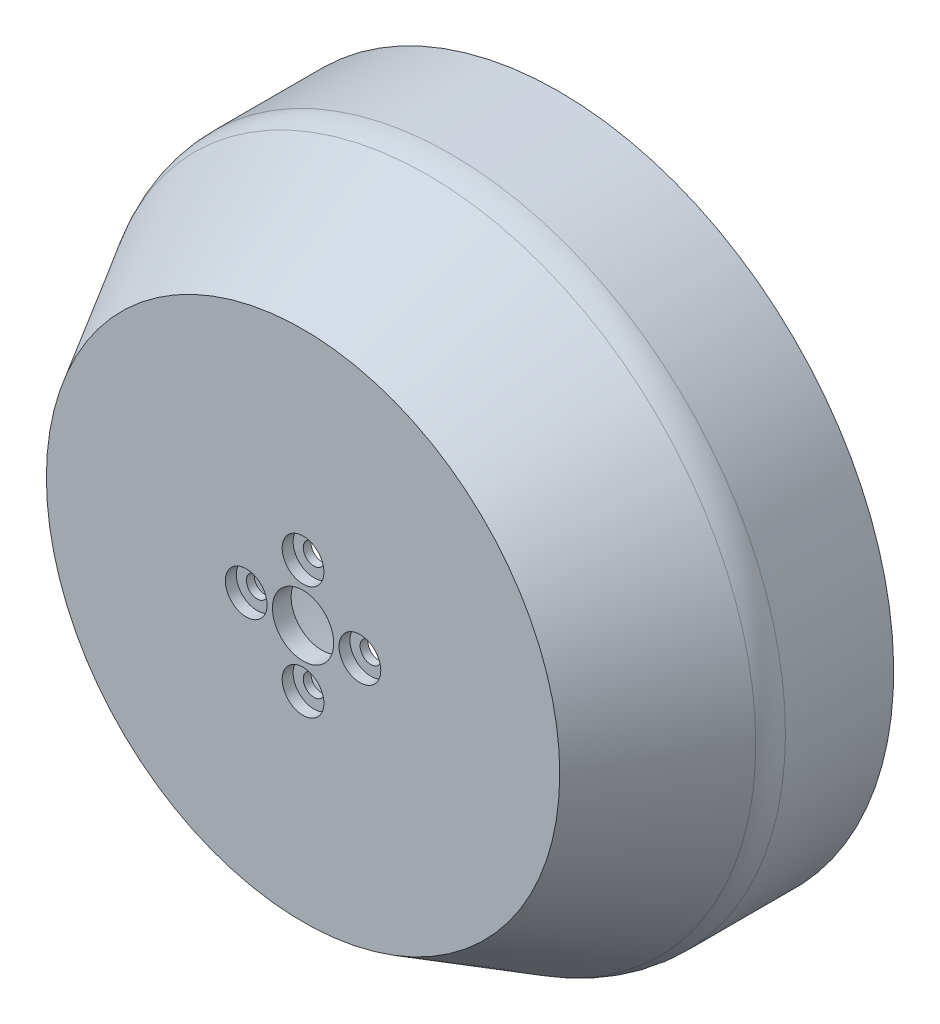
from build123d import *

# Parameters (mm, degrees)
SKETCH1_R                = 42.9
BOSS_EXTRUDE1_DEPTH      = 2.5
BOSS_EXTRUDE1_DEPTH_BACK = 30.3
CHAMFER1_SIZE            = 10
CHAMFER1_SIZE2           = 17.320508076
FILLET1_R                = 6
SHELL1_T                 = -2.4
CUT_EXTRUDE1_REACH       = 83.441
SKETCH2_R                = 3.925
SKETCH2_R_2              = 1.375
SKETCH3_R                = 2.675
CUT_EXTRUDE2_DEPTH       = 1.4


with BuildPart() as part:
    # Sketch1 → Boss-Extrude1 (new, two sides)
    with BuildSketch(Plane.XY) as boss_extrude1_sk:
        with Locations(Location((9.62, 10, 0), (0, 0, 90))):
            Circle(SKETCH1_R)
    extrude(amount=BOSS_EXTRUDE1_DEPTH)
    extrude(boss_extrude1_sk.sketch, amount=-BOSS_EXTRUDE1_DEPTH_BACK)

    # Chamfer1
    chamfer1_edges = [part.edges().sort_by_distance(p)[0] for p in [
        (9.62, -32.9, 2.5),
    ]]
    chamfer1_side = [part.faces().sort_by_distance(p)[0] for p in [
        (9.62, 10, 2.5),
    ]]
    chamfer(chamfer1_edges, length=CHAMFER1_SIZE, length2=CHAMFER1_SIZE2, reference=chamfer1_side[0])

    # Fillet1
    fillet1_edges = [part.edges().sort_by_distance(p)[0] for p in [
        (9.62, -32.9, -14.820508076),
    ]]
    fillet(fillet1_edges, radius=FILLET1_R)

    # Shell1
    shell1_openings = [part.faces().sort_by_distance(p)[0] for p in [
        (9.62, 10, -30.3),
    ]]
    offset(amount=SHELL1_T, openings=shell1_openings, kind=Kind.INTERSECTION)

    # Sketch2 → Cut-Extrude1 (cut, up to next)
    with BuildSketch(Plane.XY.offset(2.5), mode=Mode.PRIVATE) as cut_extrude1_sk1:
        with Locations((9.62, 10)):
            Circle(SKETCH2_R)
    cut_extrude1_tool1 = extrude(cut_extrude1_sk1.sketch, amount=-CUT_EXTRUDE1_REACH, mode=Mode.PRIVATE) & part.part
    # Sketch2 → Cut-Extrude1 (cut, up to next)
    with BuildSketch(Plane.XY.offset(2.5), mode=Mode.PRIVATE) as cut_extrude1_sk2:
        with Locations((9.62, 17.285)):
            Circle(SKETCH2_R_2)
    cut_extrude1_tool2 = extrude(cut_extrude1_sk2.sketch, amount=-CUT_EXTRUDE1_REACH, mode=Mode.PRIVATE) & part.part
    # Sketch2 → Cut-Extrude1 (cut, up to next)
    with BuildSketch(Plane.XY.offset(2.5), mode=Mode.PRIVATE) as cut_extrude1_sk3:
        with Locations((9.62, 2.715)):
            Circle(SKETCH2_R_2)
    cut_extrude1_tool3 = extrude(cut_extrude1_sk3.sketch, amount=-CUT_EXTRUDE1_REACH, mode=Mode.PRIVATE) & part.part
    # Sketch2 → Cut-Extrude1 (cut, up to next)
    with BuildSketch(Plane.XY.offset(2.5), mode=Mode.PRIVATE) as cut_extrude1_sk4:
        with Locations((2.335, 10)):
            Circle(SKETCH2_R_2)
    cut_extrude1_tool4 = extrude(cut_extrude1_sk4.sketch, amount=-CUT_EXTRUDE1_REACH, mode=Mode.PRIVATE) & part.part
    # Sketch2 → Cut-Extrude1 (cut, up to next)
    with BuildSketch(Plane.XY.offset(2.5), mode=Mode.PRIVATE) as cut_extrude1_sk5:
        with Locations((16.905, 10)):
            Circle(SKETCH2_R_2)
    cut_extrude1_tool5 = extrude(cut_extrude1_sk5.sketch, amount=-CUT_EXTRUDE1_REACH, mode=Mode.PRIVATE) & part.part
    add(cut_extrude1_tool1.solids().sort_by_distance((9.62, 10, 2.5))[0], mode=Mode.SUBTRACT)
    add(cut_extrude1_tool2.solids().sort_by_distance((9.62, 17.285, 2.5))[0], mode=Mode.SUBTRACT)
    add(cut_extrude1_tool3.solids().sort_by_distance((9.62, 2.715, 2.5))[0], mode=Mode.SUBTRACT)
    add(cut_extrude1_tool4.solids().sort_by_distance((2.335, 10, 2.5))[0], mode=Mode.SUBTRACT)
    add(cut_extrude1_tool5.solids().sort_by_distance((16.905, 10, 2.5))[0], mode=Mode.SUBTRACT)

    # Sketch3 → Cut-Extrude2 (cut)
    with BuildSketch(Plane.XY.offset(2.5)):
        with Locations((2.335, 10)):
            Circle(SKETCH3_R)
        with Locations((9.62, 2.715)):
            Circle(SKETCH3_R)
        with Locations((9.62, 17.285)):
            Circle(SKETCH3_R)
        with Locations((16.905, 10)):
            Circle(SKETCH3_R)
    extrude(amount=-CUT_EXTRUDE2_DEPTH, mode=Mode.SUBTRACT)


solid = part.part
